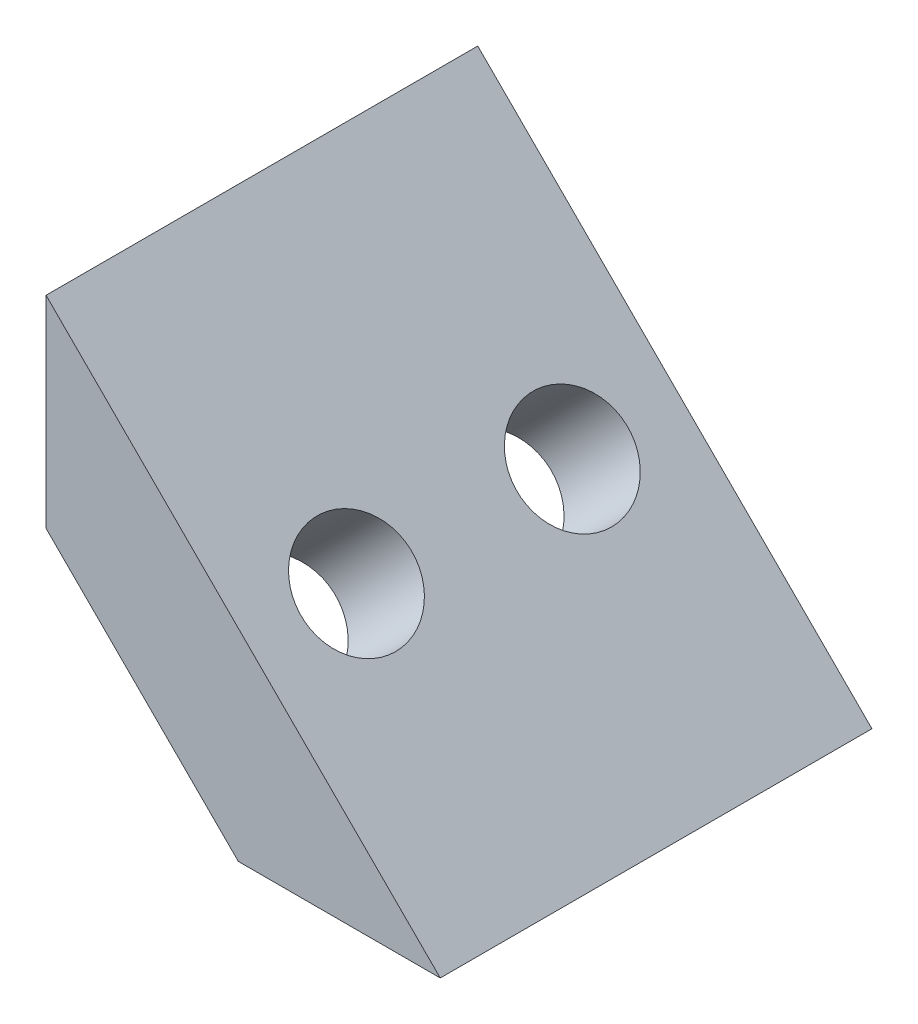
from build123d import *

# Parameters (mm, degrees)
BOSS_EXTRUDE1_DEPTH                               = 6.35
CSK_FOR_4_FLAT_HEAD_MACHINE_SCREW_100_D           = 3.2639
CSK_FOR_4_FLAT_HEAD_MACHINE_SCREW_100_CSINK_D     = 5.715
CSK_FOR_4_FLAT_HEAD_MACHINE_SCREW_100_CSINK_ANGLE = 100


with BuildPart() as part:
    # Sketch1 → Boss-Extrude1 (new body, symmetric)
    with BuildSketch(Plane.XY):
        Polygon((0, 11.596551211), (11.596551211, 0), (5.656854249, 0), (0, 5.656854249), align=None)
    extrude(amount=BOSS_EXTRUDE1_DEPTH, both=True)

    # CSK for #4 Flat Head Machine Screw (100)1 (through all)
    with Locations(Plane(origin=(2.828427125, 2.828427125, 0), x_dir=(0, 0, 1), z_dir=(-0.707106781, -0.707106781, 0))):
        with Locations((-3.175, -0.224693873), (3.175, -0.224693873)):
            CounterSinkHole(CSK_FOR_4_FLAT_HEAD_MACHINE_SCREW_100_D / 2, CSK_FOR_4_FLAT_HEAD_MACHINE_SCREW_100_CSINK_D / 2, counter_sink_angle=CSK_FOR_4_FLAT_HEAD_MACHINE_SCREW_100_CSINK_ANGLE)


solid = part.part
